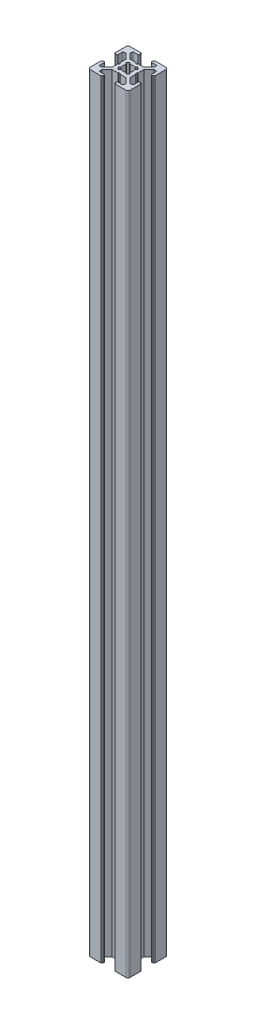
from build123d import *

# Parameters (mm, degrees)
BOSS_EXTRUDE1_DEPTH = 385
FILLET1_R           = 1
CUT_EXTRUDE1_DEPTH  = 386
FILLET2_R           = 0.5
FILLET3_R           = 0.25


with BuildPart() as part:
    # Sketch3 → Boss-Extrude1 (new body)
    with BuildSketch(Plane(origin=(0, 0, 0), x_dir=(1, 0, 0), z_dir=(0, 1, 0))):
        with BuildLine():
            Line((7, 18.5), (7, 19.5))
            ThreePointArc((7, 19.5), (6.646446609, 19.646446609), (6.5, 20))
            Line((6.5, 20), (0, 20))
            Line((0, 20), (0, 13.5))
            ThreePointArc((0, 13.5), (0.353553391, 13.353553391), (0.5, 13))
            Line((0.5, 13), (1.5, 13))
            Line((1.5, 13), (1.5, 16))
            Line((1.5, 16), (3, 16))
            Line((3, 16), (5.5, 13.5))
            Line((5.5, 13.5), (5.5, 10.5))
            Line((5.5, 10.5), (6, 10))
            Line((6, 10), (5.5, 9.5))
            Line((5.5, 9.5), (5.5, 6.5))
            Line((5.5, 6.5), (3, 4))
            Line((3, 4), (1.5, 4))
            Line((1.5, 4), (1.5, 7))
            Line((1.5, 7), (0.5, 7))
            ThreePointArc((0.5, 7), (0.353553391, 6.646446609), (0, 6.5))
            Line((0, 6.5), (0, 0))
            Line((0, 0), (6.5, 0))
            ThreePointArc((6.5, 0), (6.646446609, 0.353553391), (7, 0.5))
            Line((7, 0.5), (7, 1.5))
            Line((7, 1.5), (4, 1.5))
            Line((4, 1.5), (4, 3))
            Line((4, 3), (6.5, 5.5))
            Line((6.5, 5.5), (9.5, 5.5))
            Line((9.5, 5.5), (10, 6))
            Line((10, 6), (10.5, 5.5))
            Line((10.5, 5.5), (13.5, 5.5))
            Line((13.5, 5.5), (16, 3))
            Line((16, 3), (16, 1.5))
            Line((16, 1.5), (13, 1.5))
            Line((13, 1.5), (13, 0.5))
            ThreePointArc((13, 0.5), (13.353553391, 0.353553391), (13.5, 0))
            Line((13.5, 0), (20, 0))
            Line((20, 0), (20, 6.5))
            ThreePointArc((20, 6.5), (19.646446609, 6.646446609), (19.5, 7))
            Line((19.5, 7), (18.5, 7))
            Line((18.5, 7), (18.5, 4))
            Line((18.5, 4), (17, 4))
            Line((17, 4), (14.5, 6.5))
            Line((14.5, 6.5), (14.5, 9.5))
            Line((14.5, 9.5), (14, 10))
            Line((14, 10), (14.5, 10.5))
            Line((14.5, 10.5), (14.5, 13.5))
            Line((14.5, 13.5), (17, 16))
            Line((17, 16), (18.5, 16))
            Line((18.5, 16), (18.5, 13))
            Line((18.5, 13), (19.5, 13))
            ThreePointArc((19.5, 13), (19.646446609, 13.353553391), (20, 13.5))
            Line((20, 13.5), (20, 20))
            Line((20, 20), (13.5, 20))
            ThreePointArc((13.5, 20), (13.353553391, 19.646446609), (13, 19.5))
            Line((13, 19.5), (13, 18.5))
            Line((13, 18.5), (16, 18.5))
            Line((16, 18.5), (16, 17))
            Line((16, 17), (13.5, 14.5))
            Line((13.5, 14.5), (10.5, 14.5))
            Line((10.5, 14.5), (10, 14))
            Line((10, 14), (9.5, 14.5))
            Line((9.5, 14.5), (6.5, 14.5))
            Line((6.5, 14.5), (4, 17))
            Line((4, 17), (4, 18.5))
            Line((4, 18.5), (7, 18.5))
        make_face()
    extrude(amount=BOSS_EXTRUDE1_DEPTH)

    # Fillet1
    fillet1_edges = [part.edges().sort_by_distance(p)[0] for p in [
        (20, 192.5, 0),
        (0, 192.5, 0),
        (0, 192.5, -20),
        (20, 192.5, -20),
    ]]
    fillet(fillet1_edges, radius=FILLET1_R)

    # Sketch4 → Cut-Extrude1 (cut, through all)
    with BuildSketch(Plane(origin=(0, 385, 0), x_dir=(1, 0, 0), z_dir=(0, 1, 0))):
        with BuildLine():
            Line((10, 11), (11.195582496, 12.195582496))
            ThreePointArc((11.195582496, 12.195582496), (10, 12.5), (8.804417504, 12.195582496))
            Line((8.804417504, 12.195582496), (10, 11))
        make_face()
        with BuildLine():
            ThreePointArc((12.195582496, 11.195582496), (11.767766953, 11.767766953), (11.195582496, 12.195582496))
            Line((11.195582496, 12.195582496), (10, 11))
            Line((10, 11), (11, 10))
            Line((11, 10), (12.195582496, 11.195582496))
        make_face()
        with BuildLine():
            Line((9, 10), (10, 11))
            Line((10, 11), (8.804417504, 12.195582496))
            ThreePointArc((8.804417504, 12.195582496), (8.232233047, 11.767766953), (7.804417504, 11.195582496))
            Line((7.804417504, 11.195582496), (9, 10))
        make_face()
        Polygon((11, 10), (10, 11), (9, 10), (10, 9), align=None)
        with BuildLine():
            Line((7.804417504, 8.804417504), (9, 10))
            Line((9, 10), (7.804417504, 11.195582496))
            ThreePointArc((7.804417504, 11.195582496), (7.5, 10), (7.804417504, 8.804417504))
        make_face()
        with BuildLine():
            Line((10, 9), (9, 10))
            Line((9, 10), (7.804417504, 8.804417504))
            ThreePointArc((7.804417504, 8.804417504), (8.232233047, 8.232233047), (8.804417504, 7.804417504))
            Line((8.804417504, 7.804417504), (10, 9))
        make_face()
        with BuildLine():
            Line((11.195582496, 7.804417504), (10, 9))
            Line((10, 9), (8.804417504, 7.804417504))
            ThreePointArc((8.804417504, 7.804417504), (10, 7.5), (11.195582496, 7.804417504))
        make_face()
        with BuildLine():
            Line((12.195582496, 8.804417504), (11, 10))
            Line((11, 10), (10, 9))
            Line((10, 9), (11.195582496, 7.804417504))
            ThreePointArc((11.195582496, 7.804417504), (11.767766953, 8.232233047), (12.195582496, 8.804417504))
        make_face()
        with BuildLine():
            ThreePointArc((12.5, 10), (12.422700584, 10.616864556), (12.195582496, 11.195582496))
            Line((12.195582496, 11.195582496), (11, 10))
            Line((11, 10), (12.195582496, 8.804417504))
            ThreePointArc((12.195582496, 8.804417504), (12.422700584, 9.383135444), (12.5, 10))
        make_face()
        with BuildLine():
            ThreePointArc((8.804417504, 7.804417504), (8.232233047, 8.232233047), (7.804417504, 8.804417504))
            Line((7.804417504, 8.804417504), (7, 8))
            Line((7, 8), (8, 7))
            Line((8, 7), (8.804417504, 7.804417504))
        make_face()
        with BuildLine():
            Line((13, 8), (12.195582496, 8.804417504))
            ThreePointArc((12.195582496, 8.804417504), (11.767766953, 8.232233047), (11.195582496, 7.804417504))
            Line((11.195582496, 7.804417504), (12, 7))
            Line((12, 7), (13, 8))
        make_face()
        with BuildLine():
            Line((13, 12), (12, 13))
            Line((12, 13), (11.195582496, 12.195582496))
            ThreePointArc((11.195582496, 12.195582496), (11.767766953, 11.767766953), (12.195582496, 11.195582496))
            Line((12.195582496, 11.195582496), (13, 12))
        make_face()
        with BuildLine():
            ThreePointArc((7.804417504, 11.195582496), (8.232233047, 11.767766953), (8.804417504, 12.195582496))
            Line((8.804417504, 12.195582496), (8, 13))
            Line((8, 13), (7, 12))
            Line((7, 12), (7.804417504, 11.195582496))
        make_face()
    extrude(amount=-CUT_EXTRUDE1_DEPTH, mode=Mode.SUBTRACT)

    # Fillet2
    fillet2_edges = [part.edges().sort_by_distance(p)[0] for p in [
        (18.5, 192.5, -13),
        (18.5, 192.5, -16),
        (14.5, 192.5, -10.5),
        (14.5, 192.5, -9.5),
        (18.5, 192.5, -4),
        (18.5, 192.5, -7),
        (13, 192.5, -1.5),
        (16, 192.5, -1.5),
        (10.5, 192.5, -5.5),
        (9.5, 192.5, -5.5),
        (4, 192.5, -1.5),
        (7, 192.5, -1.5),
        (1.5, 192.5, -7),
        (1.5, 192.5, -4),
        (5.5, 192.5, -9.5),
        (5.5, 192.5, -10.5),
        (1.5, 192.5, -16),
        (1.5, 192.5, -13),
        (7, 192.5, -18.5),
        (4, 192.5, -18.5),
        (9.5, 192.5, -14.5),
        (10.5, 192.5, -14.5),
        (16, 192.5, -18.5),
        (13, 192.5, -18.5),
    ]]
    fillet(fillet2_edges, radius=FILLET2_R)

    # Fillet3
    fillet3_edges = [part.edges().sort_by_distance(p)[0] for p in [
        (7, 192.5, -12),
        (8, 192.5, -13),
        (12, 192.5, -13),
        (13, 192.5, -12),
        (13, 192.5, -8),
        (12, 192.5, -7),
        (8, 192.5, -7),
        (7, 192.5, -8),
    ]]
    fillet(fillet3_edges, radius=FILLET3_R)


solid = part.part
